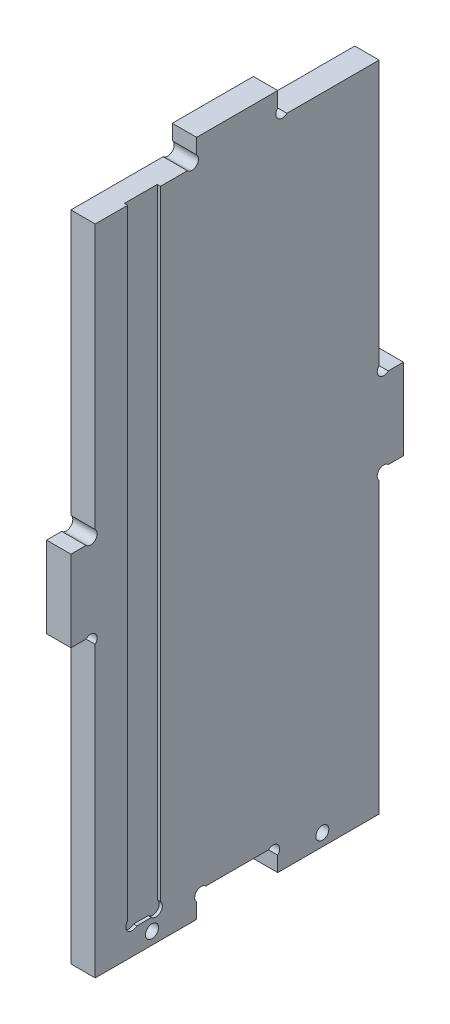
from build123d import *

# Parameters (mm, degrees)
ESQUISSE1_R             = 1.6
BOSS_EXTRU_1_DEPTH      = 6
ENL_V_MAT_EXTRU_1_DEPTH = 0.8


with BuildPart() as part:
    # Esquisse1 → Boss.-Extru.1 (new body)
    with BuildSketch(Plane(origin=(0, 0, 0), x_dir=(0, 0, -1), z_dir=(1, 0, 0))):
        with BuildLine():
            Line((3.7372583, 73.5), (0, 73.5))
            Line((0, 73.5), (0, 93.5))
            Line((0, 93.5), (3.7372583, 93.5))
            ThreePointArc((3.7372583, 93.5), (6, 93.5), (6, 95.7627417))
            Line((6, 95.7627417), (6, 161))
            Line((6, 161), (28.7372583, 161))
            ThreePointArc((28.7372583, 161), (31, 161), (31, 163.2627417))
            Line((31, 163.2627417), (31, 167))
            Line((31, 167), (51, 167))
            Line((51, 167), (51, 163.2627417))
            ThreePointArc((51, 163.2627417), (51, 161), (53.2627417, 161))
            Line((53.2627417, 161), (76, 161))
            Line((76, 161), (76, 95.7627417))
            ThreePointArc((76, 95.7627417), (76, 93.5), (78.2627417, 93.5))
            Line((78.2627417, 93.5), (82, 93.5))
            Line((82, 93.5), (82, 73.5))
            Line((82, 73.5), (78.2627417, 73.5))
            ThreePointArc((78.2627417, 73.5), (76, 73.5), (76, 71.2372583))
            Line((76, 71.2372583), (76, 0))
            Line((76, 0), (51, 0))
            Line((51, 0), (51, 3.7372583))
            ThreePointArc((51, 3.7372583), (51, 6), (48.7372583, 6))
            Line((48.7372583, 6), (33.2627417, 6))
            ThreePointArc((33.2627417, 6), (31, 6), (31, 3.7372583))
            Line((31, 3.7372583), (31, 0))
            Line((31, 0), (6, 0))
            Line((6, 0), (6, 71.2372583))
            ThreePointArc((6, 71.2372583), (6, 73.5), (3.7372583, 73.5))
        make_face()
        with Locations((20, 3)):
            Circle(ESQUISSE1_R, mode=Mode.SUBTRACT)
        with Locations(Location((62, 3, 0), (0, 0, 180))):  # turned: the seam where the file's is
            Circle(ESQUISSE1_R, mode=Mode.SUBTRACT)
    extrude(amount=BOSS_EXTRU_1_DEPTH)

    # Esquisse2 → Enlèv. mat.-Extru.1 (cut)
    with BuildSketch(Plane.ZY.offset(-6)):
        with BuildLine():
            Line((-22.1, 165.86112534), (-14, 165.86112534))
            Line((-14, 165.86112534), (-14, 8.2627417))
            ThreePointArc((-14, 8.2627417), (-14, 6), (-16.2627417, 6))
            Line((-16.2627417, 6), (-19.8372583, 6))
            ThreePointArc((-19.8372583, 6), (-22.1, 6), (-22.1, 8.2627417))
            Line((-22.1, 8.2627417), (-22.1, 165.86112534))
        make_face()
    extrude(amount=ENL_V_MAT_EXTRU_1_DEPTH, mode=Mode.SUBTRACT)


solid = part.part
